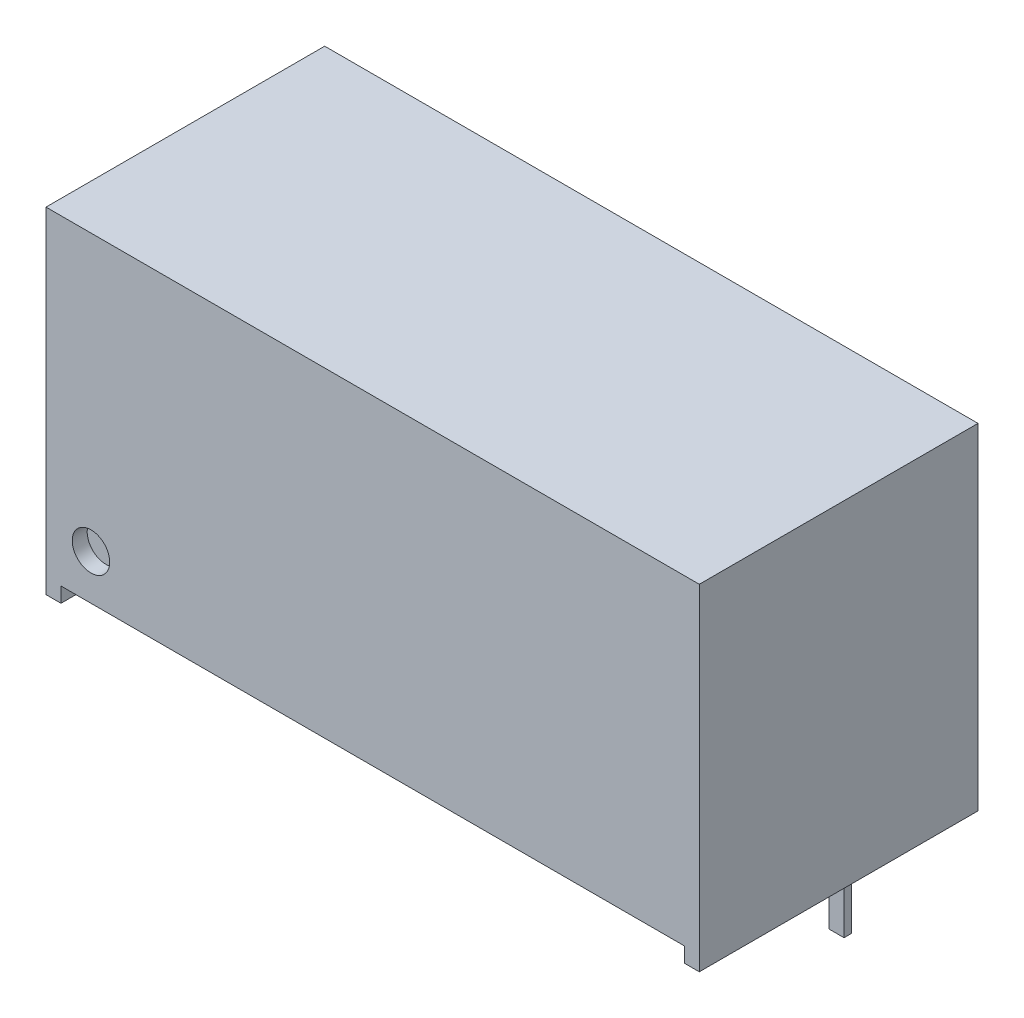
from build123d import *

# Parameters (mm, degrees)
BOSS_EXTRUDE1_DEPTH = 9.3
SKETCH3_W           = 0.5
SKETCH3_H           = 0.25
BOSS_EXTRUDE2_DEPTH = 3.7
SKETCH4_R           = 0.625
CUT_EXTRUDE1_DEPTH  = 0.5


with BuildPart() as part:
    # Sketch2 → Boss-Extrude1 (new body)
    with BuildSketch(Plane.XY):
        Polygon((0, 0), (0, 11.2), (21.8, 11.2), (21.8, 0), (21.3, 0), (21.3, 0.5), (0.5, 0.5), (0.5, 0), align=None)
    extrude(amount=BOSS_EXTRUDE1_DEPTH)

    # Sketch3 → Boss-Extrude2 (add)
    with BuildSketch(Plane.XZ.offset(-0.5)):
        with Locations((2, 2.575)):
            Rectangle(SKETCH3_W, SKETCH3_H)
        with Locations((4.54, 2.575)):
            Rectangle(SKETCH3_W, SKETCH3_H)
        with Locations((7.08, 2.575)):
            Rectangle(SKETCH3_W, SKETCH3_H)
        with Locations((12.16, 2.575)):
            Rectangle(SKETCH3_W, SKETCH3_H)
        with Locations((14.7, 2.575)):
            Rectangle(SKETCH3_W, SKETCH3_H)
        with Locations((17.24, 2.575)):
            Rectangle(SKETCH3_W, SKETCH3_H)
        with Locations((19.78, 2.575)):
            Rectangle(SKETCH3_W, SKETCH3_H)
    extrude(amount=BOSS_EXTRUDE2_DEPTH)

    # Sketch4 → Cut-Extrude1 (cut)
    with BuildSketch(Plane.XY.offset(9.3)):
        with Locations((1.5, 2)):
            Circle(SKETCH4_R)
    extrude(amount=-CUT_EXTRUDE1_DEPTH, mode=Mode.SUBTRACT)


solid = part.part
